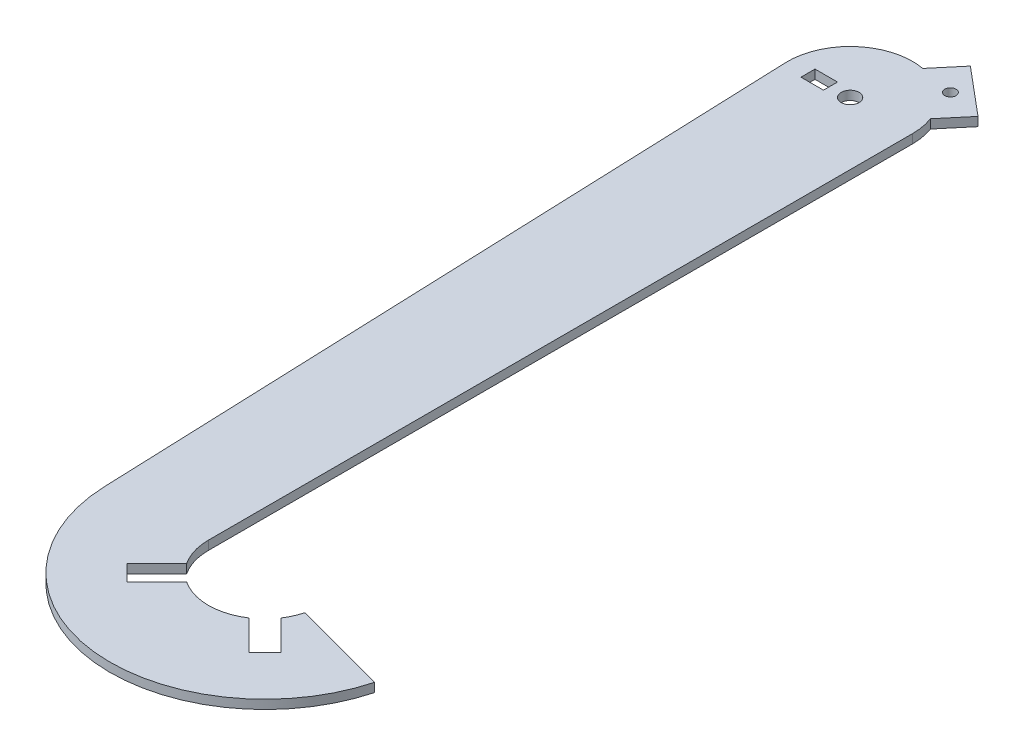
from build123d import *

# Parameters (mm, degrees)
SKETCH1_R           = 3.175
SKETCH1_R_2         = 2
SKETCH1_W           = 8
SKETCH1_H           = 5
BOSS_EXTRUDE1_DEPTH = 1.5875


with BuildPart() as part:
    # Sketch1 → Boss-Extrude1 (new body, symmetric)
    with BuildSketch(Plane(origin=(0, 0, 0), x_dir=(1, 0, 0), z_dir=(0, 1, 0))):
        with BuildLine():
            Line((22.225, 0), (22.225, -250.448449629))
            ThreePointArc((22.225, -250.448449629), (23.079031542, -256.245526228), (25.568559237, -261.550026094))
            Line((25.568559237, -261.550026094), (14.961957519, -272.156627812))
            Line((14.961957519, -272.156627812), (20.618811769, -277.813482061))
            Line((20.618811769, -277.813482061), (31.225413487, -267.206880343))
            ThreePointArc((31.225413487, -267.206880343), (42.326989951, -270.55043958), (53.428566416, -267.206880343))
            Line((53.428566416, -267.206880343), (64.035168134, -277.813482061))
            Line((64.035168134, -277.813482061), (69.692022383, -272.156627812))
            Line((69.692022383, -272.156627812), (59.085420665, -261.550026094))
            ThreePointArc((59.085420665, -261.550026094), (60.653609073, -258.708294153), (61.744021205, -255.651227473))
            Line((61.744021205, -255.651227473), (95.551425125, -264.709894052))
            ThreePointArc((95.551425125, -264.709894052), (36.163593878, -305.204653346), (-12.736009339, -252.520985708))
            Line((-12.736009339, -252.520985708), (-22.209273391, -0.835942847))
            ThreePointArc((-22.209273391, -0.835942847), (-14.554726567, 16.796147164), (3.986980194, 21.864460065))
            Line((3.986980194, 21.864460065), (11.70043151, 31.056993382))
            Line((11.70043151, 31.056993382), (28.553409259, 16.915665969))
            Line((28.553409259, 16.915665969), (20.839957942, 7.723132652))
            ThreePointArc((20.839957942, 7.723132652), (21.875999295, 3.923172169), (22.225, 0))
        make_face()
        Circle(SKETCH1_R, mode=Mode.SUBTRACT)
        with Locations((16.270194726, 19.390063017)):
            Circle(SKETCH1_R_2, mode=Mode.SUBTRACT)
        with Locations((-11, 0)):
            Rectangle(SKETCH1_W, SKETCH1_H, mode=Mode.SUBTRACT)
    extrude(amount=BOSS_EXTRUDE1_DEPTH, both=True)


solid = part.part
